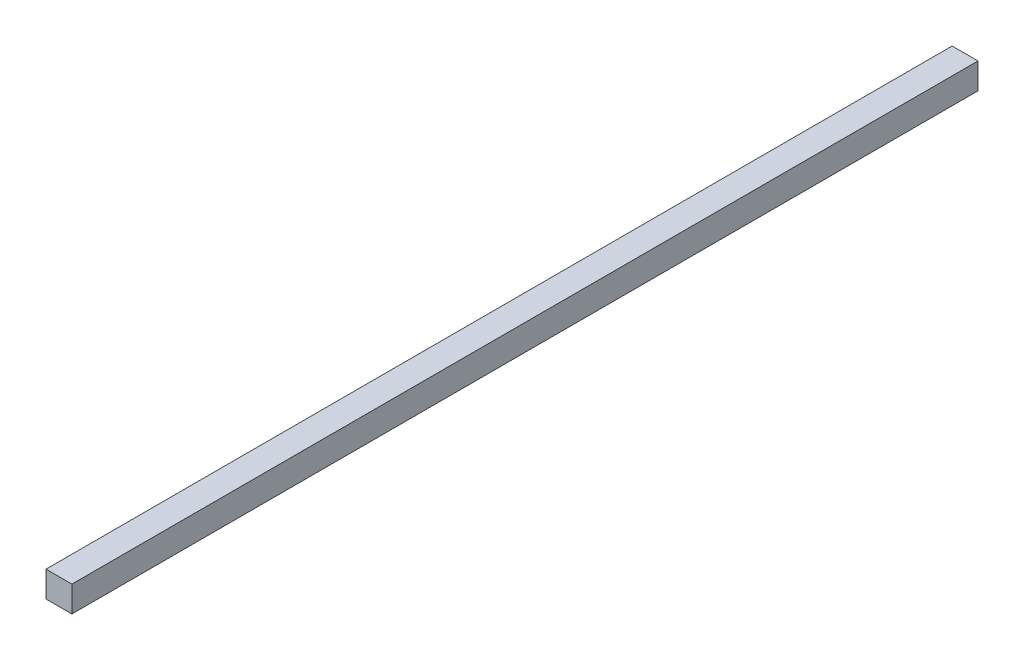
from build123d import *

# Parameters (mm, degrees)
SKETCH2_W           = 10
SKETCH2_H           = 10
BOSS_EXTRUDE1_DEPTH = 350


with BuildPart() as part:
    # Sketch2 → Boss-Extrude1 (new body)
    with BuildSketch(Plane.XY):
        Rectangle(SKETCH2_W, SKETCH2_H)
    extrude(amount=BOSS_EXTRUDE1_DEPTH)


solid = part.part
